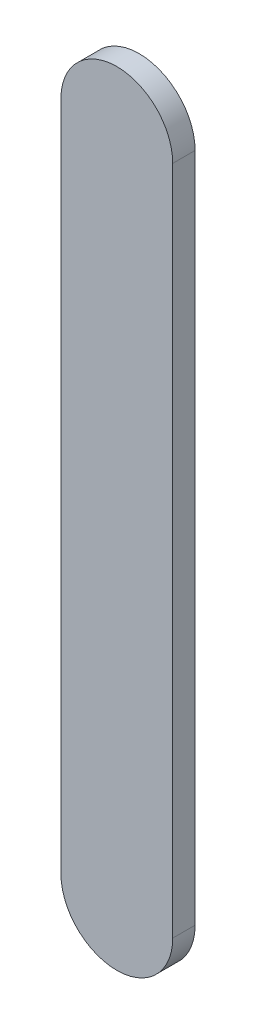
from build123d import *

# Parameters (mm, degrees)
BOSS_EXTRUDE1_DEPTH = 1


with BuildPart() as part:
    # Sketch1 → Boss-Extrude1 (new body)
    with BuildSketch(Plane.XY):
        with BuildLine():
            Line((9.283789279, 6.579531591), (9.283789279, -23.420468409))
            ThreePointArc((9.283789279, -23.420468409), (6.783789279, -25.920468409), (4.283789279, -23.420468409))
            Line((4.283789279, -23.420468409), (4.283789279, 6.579531591))
            ThreePointArc((4.283789279, 6.579531591), (6.783789279, 9.079531591), (9.283789279, 6.579531591))
        make_face()
    extrude(amount=BOSS_EXTRUDE1_DEPTH)


solid = part.part
